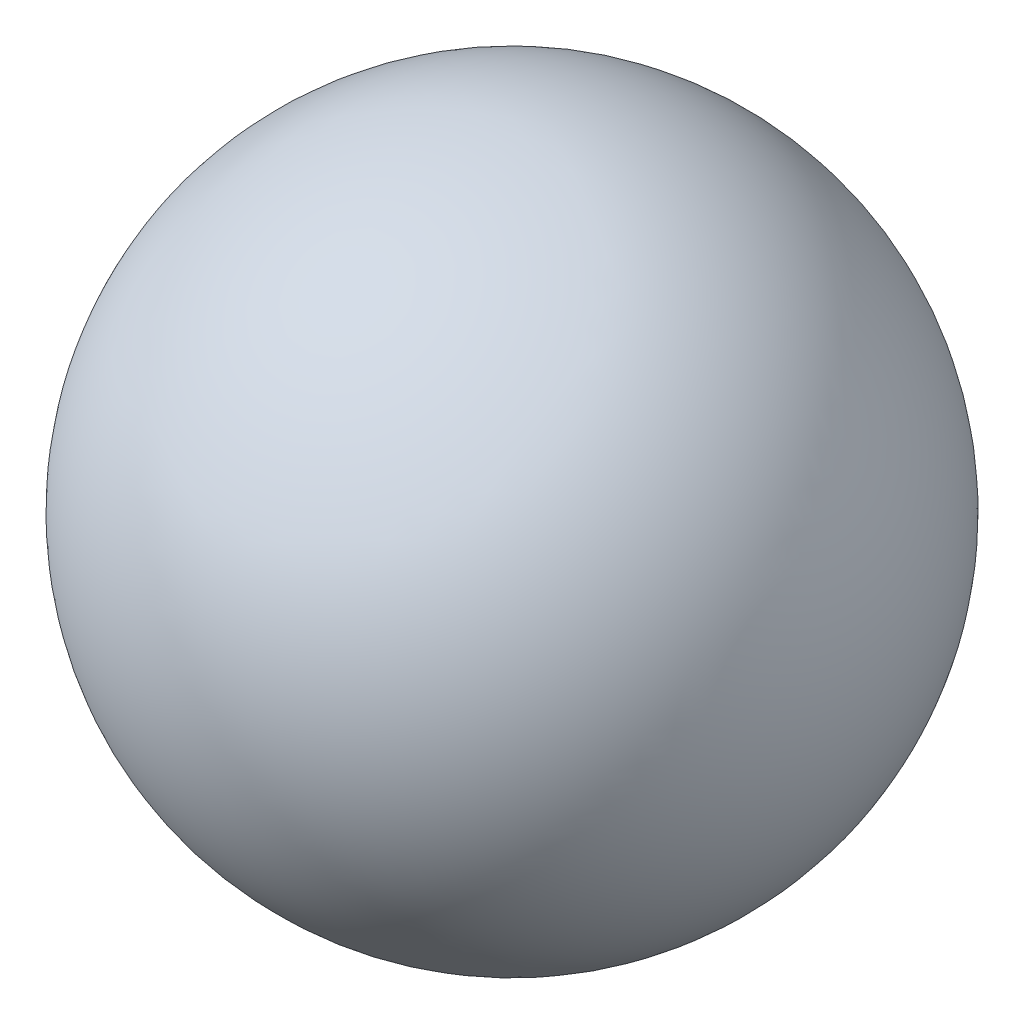
from build123d import *


with BuildPart() as part:
    # Sketch1 → Revolve1 (revolve)
    with BuildSketch(Plane(origin=(0, 0, 0), x_dir=(1, 0, 0), z_dir=(0, 1, 0))):
        with BuildLine():
            Line((-2.9718, 0), (2.9718, 0))
            ThreePointArc((2.9718, 0), (0, 2.9718), (-2.9718, 0))
        make_face()
    revolve(axis=Axis((-2.9718, 0, 0), (1, 0, 0)))


solid = part.part
